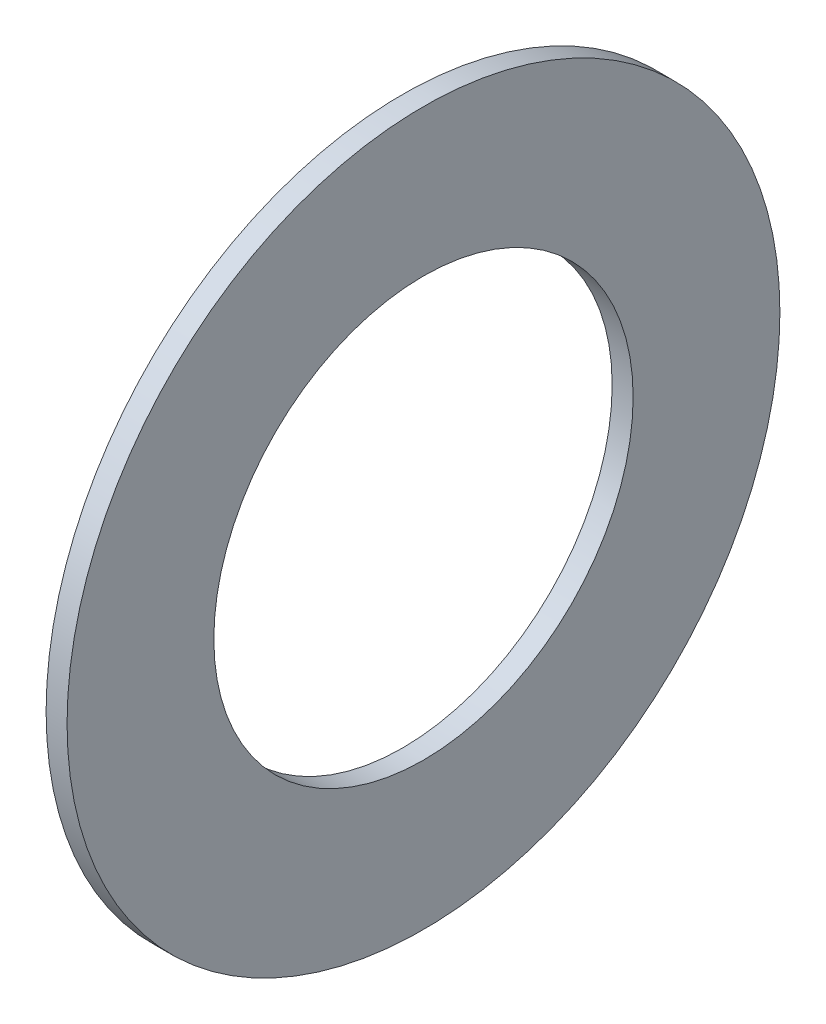
from build123d import *

# Parameters (mm, degrees)
SKETCH1_W = 1
SKETCH1_H = 7


with BuildPart() as part:
    # Sketch1 → Revolve1 (revolve)
    with BuildSketch(Plane.XY):
        with Locations((-1.5, 13.5)):
            Rectangle(SKETCH1_W, SKETCH1_H)
    revolve(axis=Axis((50, 0, 0), (-1, 0, 0)))


solid = part.part
